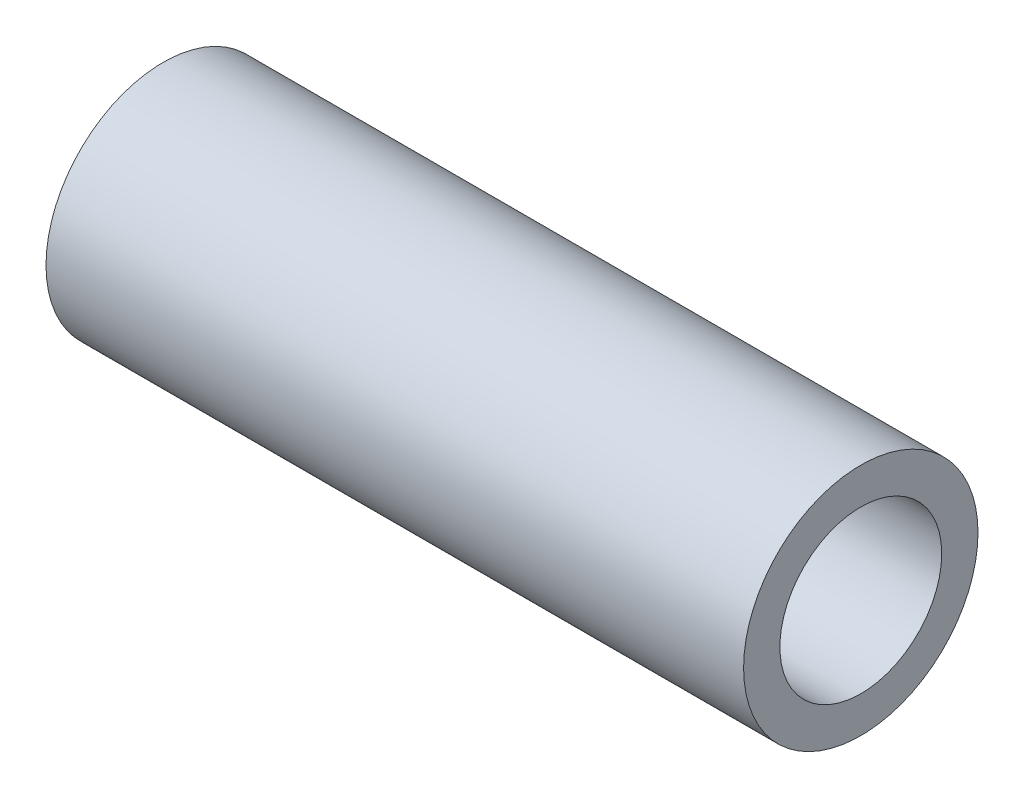
from build123d import *

# Parameters (mm, degrees)
SKETCH1_R           = 10.668
SKETCH1_R_2         = 7.366
BOSS_EXTRUDE1_DEPTH = 63.5


with BuildPart() as part:
    # Sketch1 → Boss-Extrude1 (new body)
    with BuildSketch(Plane(origin=(0, 0, 0), x_dir=(0, 0, -1), z_dir=(1, 0, 0))):
        Circle(SKETCH1_R)
        Circle(SKETCH1_R_2, mode=Mode.SUBTRACT)
    extrude(amount=-BOSS_EXTRUDE1_DEPTH)


solid = part.part
